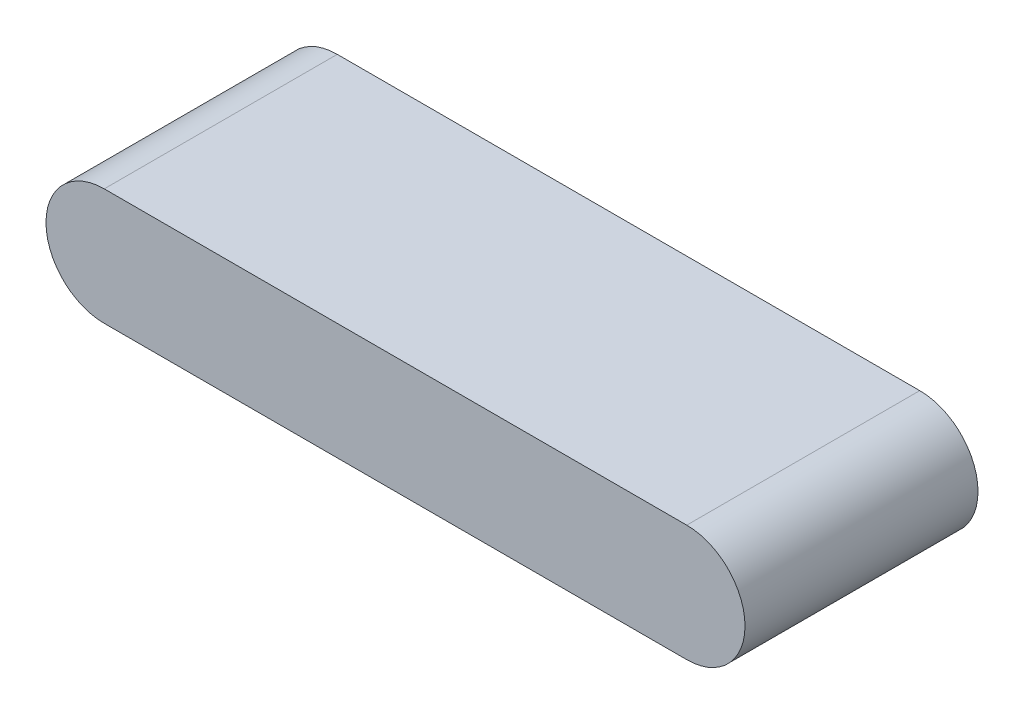
from build123d import *

# Parameters (mm, degrees)
BOSS_EXTRUDE1_DEPTH = 25.4


with BuildPart() as part:
    # Sketch1 → Boss-Extrude1 (new body, symmetric)
    with BuildSketch(Plane.XY):
        with BuildLine():
            Line((-53.798308188, 12.7), (73.201691812, 12.7))
            ThreePointArc((73.201691812, 12.7), (85.901691812, 0), (73.201691812, -12.7))
            Line((73.201691812, -12.7), (-53.798308188, -12.7))
            ThreePointArc((-53.798308188, -12.7), (-66.498308188, 0), (-53.798308188, 12.7))
        make_face()
    extrude(amount=BOSS_EXTRUDE1_DEPTH, both=True)


solid = part.part
